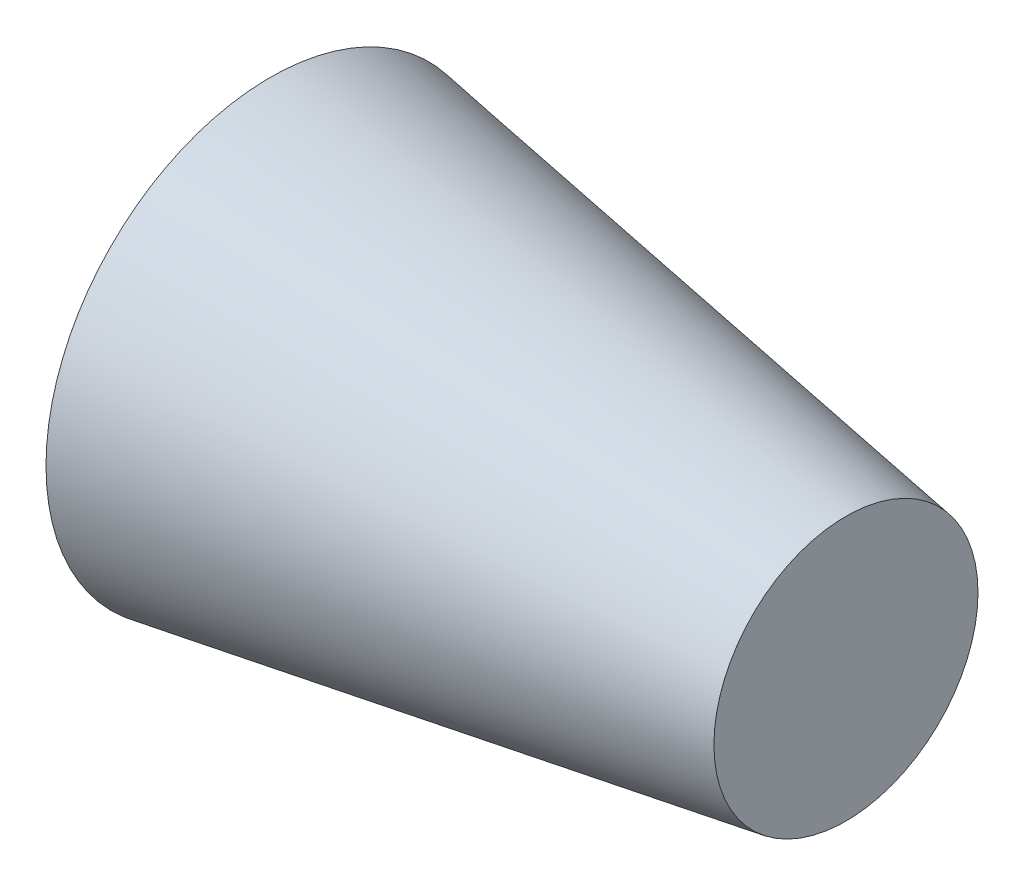
from build123d import *


with BuildPart() as part:
    # Sketch1 → Revolve1 (revolve)
    with BuildSketch(Plane.XY):
        Polygon((20094.535486919, 828.764756447), (17192.239866631, 1293.602117177), (17192.239866631, 163.10810016), (20094.535486919, 163.10810016), align=None)
    revolve(axis=Axis((17192.239866631, 163.10810016, 0), (1, 0, 0)))


solid = part.part
